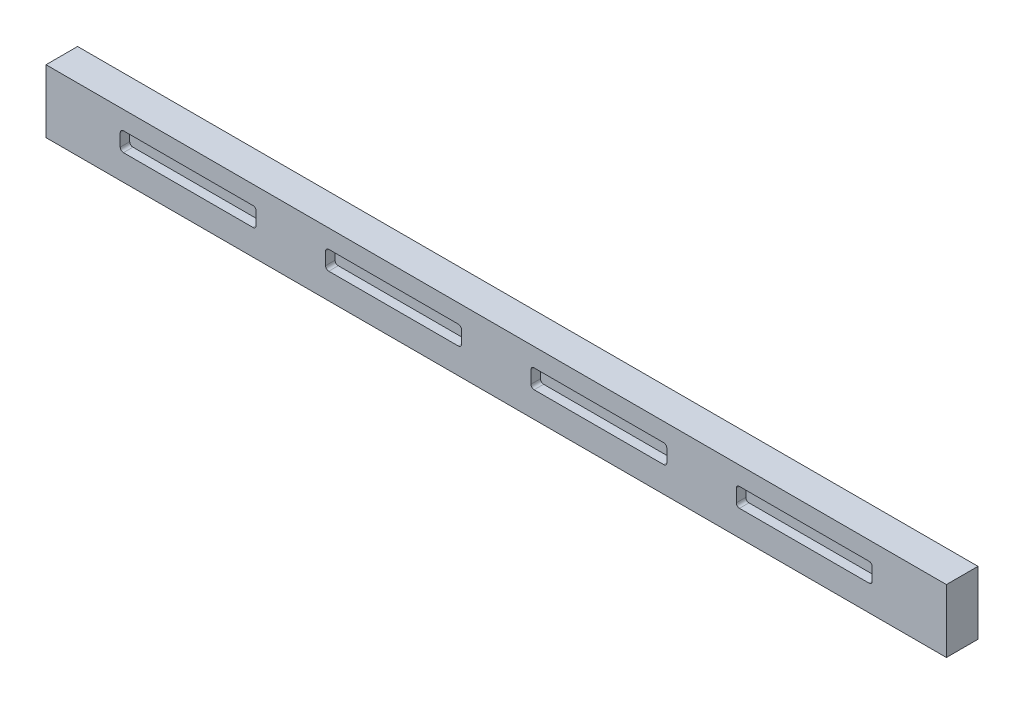
from build123d import *

# Parameters (mm, degrees)
SKETCH1_W           = 285
SKETCH1_H           = 20
BOSS_EXTRUDE1_DEPTH = 10
SKETCH5_W           = 43
SKETCH5_H           = 6
CUT_EXTRUDE1_DEPTH  = 3
FILLET1_R           = 1


with BuildPart() as part:
    # Sketch1 → Boss-Extrude1 (new body)
    with BuildSketch(Plane.XY.offset(27.5)):
        with Locations((0, 13)):
            Rectangle(SKETCH1_W, SKETCH1_H)
    extrude(amount=BOSS_EXTRUDE1_DEPTH)

    # Sketch5 → Cut-Extrude1 (cut)
    with BuildSketch(Plane.XY.offset(37.5)):
        with Locations((-97.5, 14.15)):
            Rectangle(SKETCH5_W, SKETCH5_H)
        with Locations((-32.5, 14.15)):
            Rectangle(SKETCH5_W, SKETCH5_H)
        with Locations((32.5, 14.15)):
            Rectangle(SKETCH5_W, SKETCH5_H)
        with Locations((97.5, 14.15)):
            Rectangle(SKETCH5_W, SKETCH5_H)
    extrude(amount=-CUT_EXTRUDE1_DEPTH, mode=Mode.SUBTRACT)

    # Fillet1
    fillet1_edges = [part.edges().sort_by_distance(p)[0] for p in [
        (-76, 17.15, 36),
        (-76, 11.15, 36),
        (-119, 11.15, 36),
        (-119, 17.15, 36),
        (-11, 17.15, 36),
        (-11, 11.15, 36),
        (-54, 11.15, 36),
        (-54, 17.15, 36),
        (54, 17.15, 36),
        (54, 11.15, 36),
        (11, 11.15, 36),
        (11, 17.15, 36),
        (119, 17.15, 36),
        (119, 11.15, 36),
        (76, 11.15, 36),
        (76, 17.15, 36),
    ]]
    fillet(fillet1_edges, radius=FILLET1_R)


solid = part.part
